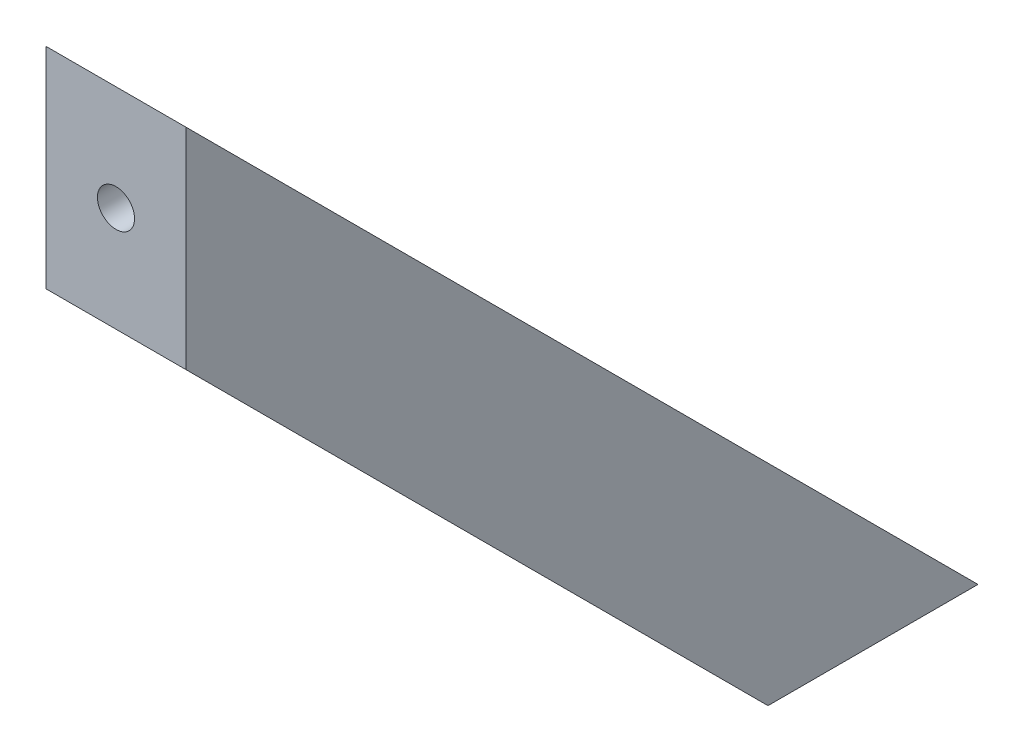
from build123d import *

# Parameters (mm, degrees)
BOSS_EXTRUDE1_DEPTH = 20
SKETCH3_R           = 2.65
CUT_EXTRUDE1_DEPTH  = 114.13708499
SKETCH4_R           = 2.65
CUT_EXTRUDE2_DEPTH  = 114.13708499
SKETCH5_R           = 5.5
CUT_EXTRUDE3_DEPTH  = 109.13708499
SKETCH6_R           = 5.5
CUT_EXTRUDE4_DEPTH  = 109.13708499


with BuildPart() as part:
    # Sketch2 → Boss-Extrude1 (new body)
    with BuildSketch(Plane(origin=(0, 0, 0), x_dir=(0, 0, -1), z_dir=(1, 0, 0))):
        Polygon((0, 0), (-83.13708499, 83.13708499), (-83.13708499, 113.13708499), (30, 0), align=None)
    extrude(amount=BOSS_EXTRUDE1_DEPTH)

    # Sketch3 → Cut-Extrude1 (cut, through all)
    with BuildSketch(Plane.XZ):
        with Locations((10, -15)):
            Circle(SKETCH3_R)
    extrude(amount=-CUT_EXTRUDE1_DEPTH, mode=Mode.SUBTRACT)

    # Sketch4 → Cut-Extrude2 (cut, through all)
    with BuildSketch(Plane.XY.offset(83.13708499)):
        with Locations((10, 98.13708499)):
            Circle(SKETCH4_R)
    extrude(amount=-CUT_EXTRUDE2_DEPTH, mode=Mode.SUBTRACT)

    # Sketch5 → Cut-Extrude3 (cut, through all)
    with BuildSketch(Plane.XY.offset(78.13708499)):
        with Locations((10, 98.13708499)):
            Circle(SKETCH5_R)
    extrude(amount=-CUT_EXTRUDE3_DEPTH, mode=Mode.SUBTRACT)

    # Sketch6 → Cut-Extrude4 (cut, through all)
    with BuildSketch(Plane(origin=(0, 5, 0), x_dir=(-1, 0, 0), z_dir=(0, -1, 0))):
        with Locations((-10, 15)):
            Circle(SKETCH6_R)
    extrude(amount=-CUT_EXTRUDE4_DEPTH, mode=Mode.SUBTRACT)


solid = part.part
